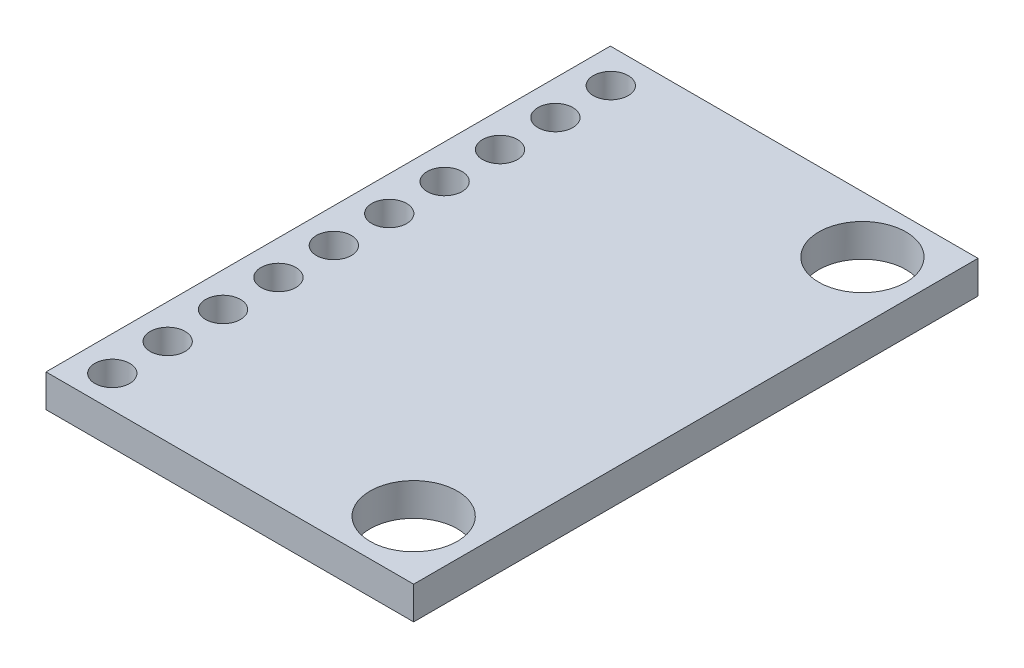
from build123d import *

# Parameters (mm, degrees)
SKETCH1_W           = 16.86
SKETCH1_H           = 25.88
BOSS_EXTRUDE1_DEPTH = 1.5
CUT_EXTRUDE1_REACH  = 3.5
SKETCH2_R           = 2
CUT_EXTRUDE2_REACH  = 3.5
SKETCH3_R           = 0.8


with BuildPart() as part:
    # Sketch1 → Boss-Extrude1 (new body)
    with BuildSketch(Plane(origin=(0, 0, 0), x_dir=(1, 0, 0), z_dir=(0, 1, 0))):
        with Locations((8.43, 12.94)):
            Rectangle(SKETCH1_W, SKETCH1_H)
    extrude(amount=BOSS_EXTRUDE1_DEPTH)

    # Sketch2 → Cut-Extrude1 (cut, up to next)
    with BuildSketch(Plane(origin=(0, 1.5, 0), x_dir=(1, 0, 0), z_dir=(0, 1, 0)), mode=Mode.PRIVATE) as cut_extrude1_sk1:
        with Locations((14.16, 23.28)):
            Circle(SKETCH2_R)
    cut_extrude1_tool1 = extrude(cut_extrude1_sk1.sketch, amount=-CUT_EXTRUDE1_REACH, mode=Mode.PRIVATE) & part.part
    add(cut_extrude1_tool1.solids().sort_by_distance((14.16, 1.5, -23.28))[0], mode=Mode.SUBTRACT)
    # Sketch2 → Cut-Extrude1 (cut, up to next)
    with BuildSketch(Plane(origin=(0, 1.5, 0), x_dir=(1, 0, 0), z_dir=(0, 1, 0)), mode=Mode.PRIVATE) as cut_extrude1_sk2:
        with Locations((14.16, 2.7)):
            Circle(SKETCH2_R)
    cut_extrude1_tool2 = extrude(cut_extrude1_sk2.sketch, amount=-CUT_EXTRUDE1_REACH, mode=Mode.PRIVATE) & part.part
    add(cut_extrude1_tool2.solids().sort_by_distance((14.16, 1.5, -2.7))[0], mode=Mode.SUBTRACT)

    # Sketch3 → Cut-Extrude2 (cut, up to next)
    with BuildSketch(Plane(origin=(0, 1.5, 0), x_dir=(1, 0, 0), z_dir=(0, 1, 0)), mode=Mode.PRIVATE) as cut_extrude2_sk1:
        with Locations((1.58, 24.32)):
            Circle(SKETCH3_R)
    cut_extrude2_tool1 = extrude(cut_extrude2_sk1.sketch, amount=-CUT_EXTRUDE2_REACH, mode=Mode.PRIVATE) & part.part
    add(cut_extrude2_tool1.solids().sort_by_distance((1.58, 1.5, -24.32))[0], mode=Mode.SUBTRACT)
    # Sketch3 → Cut-Extrude2 (cut, up to next)
    with BuildSketch(Plane(origin=(0, 1.5, 0), x_dir=(1, 0, 0), z_dir=(0, 1, 0)), mode=Mode.PRIVATE) as cut_extrude2_sk2:
        with Locations((1.58, 21.78)):
            Circle(SKETCH3_R)
    cut_extrude2_tool2 = extrude(cut_extrude2_sk2.sketch, amount=-CUT_EXTRUDE2_REACH, mode=Mode.PRIVATE) & part.part
    add(cut_extrude2_tool2.solids().sort_by_distance((1.58, 1.5, -21.78))[0], mode=Mode.SUBTRACT)
    # Sketch3 → Cut-Extrude2 (cut, up to next)
    with BuildSketch(Plane(origin=(0, 1.5, 0), x_dir=(1, 0, 0), z_dir=(0, 1, 0)), mode=Mode.PRIVATE) as cut_extrude2_sk3:
        with Locations((1.58, 19.24)):
            Circle(SKETCH3_R)
    cut_extrude2_tool3 = extrude(cut_extrude2_sk3.sketch, amount=-CUT_EXTRUDE2_REACH, mode=Mode.PRIVATE) & part.part
    add(cut_extrude2_tool3.solids().sort_by_distance((1.58, 1.5, -19.24))[0], mode=Mode.SUBTRACT)
    # Sketch3 → Cut-Extrude2 (cut, up to next)
    with BuildSketch(Plane(origin=(0, 1.5, 0), x_dir=(1, 0, 0), z_dir=(0, 1, 0)), mode=Mode.PRIVATE) as cut_extrude2_sk4:
        with Locations((1.58, 16.7)):
            Circle(SKETCH3_R)
    cut_extrude2_tool4 = extrude(cut_extrude2_sk4.sketch, amount=-CUT_EXTRUDE2_REACH, mode=Mode.PRIVATE) & part.part
    add(cut_extrude2_tool4.solids().sort_by_distance((1.58, 1.5, -16.7))[0], mode=Mode.SUBTRACT)
    # Sketch3 → Cut-Extrude2 (cut, up to next)
    with BuildSketch(Plane(origin=(0, 1.5, 0), x_dir=(1, 0, 0), z_dir=(0, 1, 0)), mode=Mode.PRIVATE) as cut_extrude2_sk5:
        with Locations((1.58, 14.16)):
            Circle(SKETCH3_R)
    cut_extrude2_tool5 = extrude(cut_extrude2_sk5.sketch, amount=-CUT_EXTRUDE2_REACH, mode=Mode.PRIVATE) & part.part
    add(cut_extrude2_tool5.solids().sort_by_distance((1.58, 1.5, -14.16))[0], mode=Mode.SUBTRACT)
    # Sketch3 → Cut-Extrude2 (cut, up to next)
    with BuildSketch(Plane(origin=(0, 1.5, 0), x_dir=(1, 0, 0), z_dir=(0, 1, 0)), mode=Mode.PRIVATE) as cut_extrude2_sk6:
        with Locations((1.58, 11.62)):
            Circle(SKETCH3_R)
    cut_extrude2_tool6 = extrude(cut_extrude2_sk6.sketch, amount=-CUT_EXTRUDE2_REACH, mode=Mode.PRIVATE) & part.part
    add(cut_extrude2_tool6.solids().sort_by_distance((1.58, 1.5, -11.62))[0], mode=Mode.SUBTRACT)
    # Sketch3 → Cut-Extrude2 (cut, up to next)
    with BuildSketch(Plane(origin=(0, 1.5, 0), x_dir=(1, 0, 0), z_dir=(0, 1, 0)), mode=Mode.PRIVATE) as cut_extrude2_sk7:
        with Locations((1.58, 9.08)):
            Circle(SKETCH3_R)
    cut_extrude2_tool7 = extrude(cut_extrude2_sk7.sketch, amount=-CUT_EXTRUDE2_REACH, mode=Mode.PRIVATE) & part.part
    add(cut_extrude2_tool7.solids().sort_by_distance((1.58, 1.5, -9.08))[0], mode=Mode.SUBTRACT)
    # Sketch3 → Cut-Extrude2 (cut, up to next)
    with BuildSketch(Plane(origin=(0, 1.5, 0), x_dir=(1, 0, 0), z_dir=(0, 1, 0)), mode=Mode.PRIVATE) as cut_extrude2_sk8:
        with Locations((1.58, 6.54)):
            Circle(SKETCH3_R)
    cut_extrude2_tool8 = extrude(cut_extrude2_sk8.sketch, amount=-CUT_EXTRUDE2_REACH, mode=Mode.PRIVATE) & part.part
    add(cut_extrude2_tool8.solids().sort_by_distance((1.58, 1.5, -6.54))[0], mode=Mode.SUBTRACT)
    # Sketch3 → Cut-Extrude2 (cut, up to next)
    with BuildSketch(Plane(origin=(0, 1.5, 0), x_dir=(1, 0, 0), z_dir=(0, 1, 0)), mode=Mode.PRIVATE) as cut_extrude2_sk9:
        with Locations((1.58, 4)):
            Circle(SKETCH3_R)
    cut_extrude2_tool9 = extrude(cut_extrude2_sk9.sketch, amount=-CUT_EXTRUDE2_REACH, mode=Mode.PRIVATE) & part.part
    add(cut_extrude2_tool9.solids().sort_by_distance((1.58, 1.5, -4))[0], mode=Mode.SUBTRACT)
    # Sketch3 → Cut-Extrude2 (cut, up to next)
    with BuildSketch(Plane(origin=(0, 1.5, 0), x_dir=(1, 0, 0), z_dir=(0, 1, 0)), mode=Mode.PRIVATE) as cut_extrude2_sk10:
        with Locations((1.58, 1.46)):
            Circle(SKETCH3_R)
    cut_extrude2_tool10 = extrude(cut_extrude2_sk10.sketch, amount=-CUT_EXTRUDE2_REACH, mode=Mode.PRIVATE) & part.part
    add(cut_extrude2_tool10.solids().sort_by_distance((1.58, 1.5, -1.46))[0], mode=Mode.SUBTRACT)


solid = part.part
